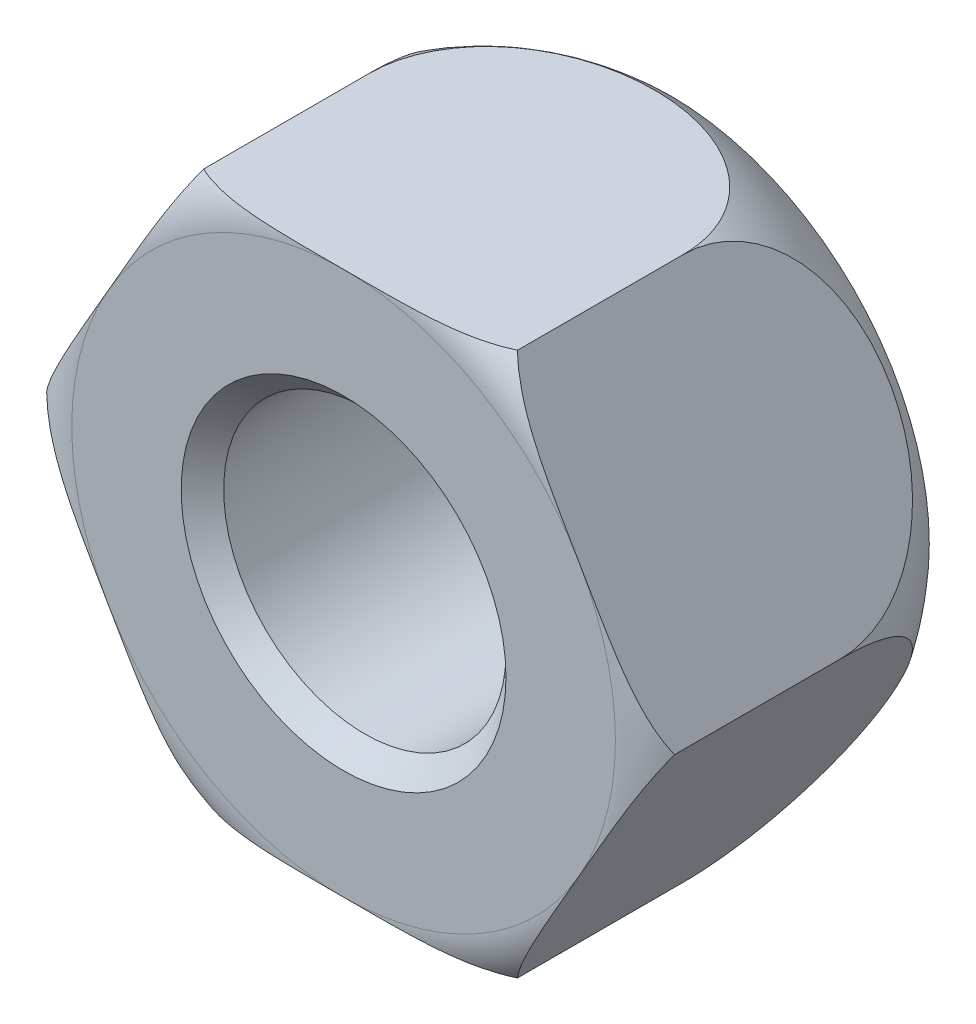
from build123d import *

# Parameters (mm, degrees)
SKETCH1_R           = 3.3235
BOSS_EXTRUDE1_DEPTH = 7.7
CHAMFER1_SIZE       = 0.5


with BuildPart() as part:
    # Sketch1 → Boss-Extrude1 (new body)
    with BuildSketch(Plane.XY):
        Polygon((3.695041723, 6.4), (-3.695041723, 6.4), (-7.390083446, 0), (-3.695041723, -6.4), (3.695041723, -6.4), (7.390083446, 0), align=None)
        Circle(SKETCH1_R, mode=Mode.SUBTRACT)
    extrude(amount=-BOSS_EXTRUDE1_DEPTH)

    # Sketch2 → Cut-Revolve1 (revolve, cut)
    with BuildSketch(Plane(origin=(0, 0, 0), x_dir=(1, 0, 0), z_dir=(0, 1, 0))):
        with BuildLine():
            Line((-7.390083446, 7.7), (-7.390083446, 4.3))
            ThreePointArc((-7.390083446, 4.3), (-7.05400145, 6.120027472), (-6.090083446, 7.7))
            Line((-6.090083446, 7.7), (-7.390083446, 7.7))
        make_face()
        with BuildLine():
            Line((-7.390083446, 0), (-7.390083446, 0.4))
            ThreePointArc((-7.390083446, 0.4), (-6.933916011, 0.103778026), (-6.4, 0))
            Line((-6.4, 0), (-7.390083446, 0))
        make_face()
    revolve(axis=Axis((0, 0, -8.105120256), (0, 0, 1)), mode=Mode.SUBTRACT)

    # Chamfer1
    chamfer1_edges = [part.edges().sort_by_distance(p)[0] for p in [
        (-3.3235, 0, -7.7),
        (-3.3235, 0, 0),
    ]]
    chamfer(chamfer1_edges, length=CHAMFER1_SIZE)


solid = part.part
